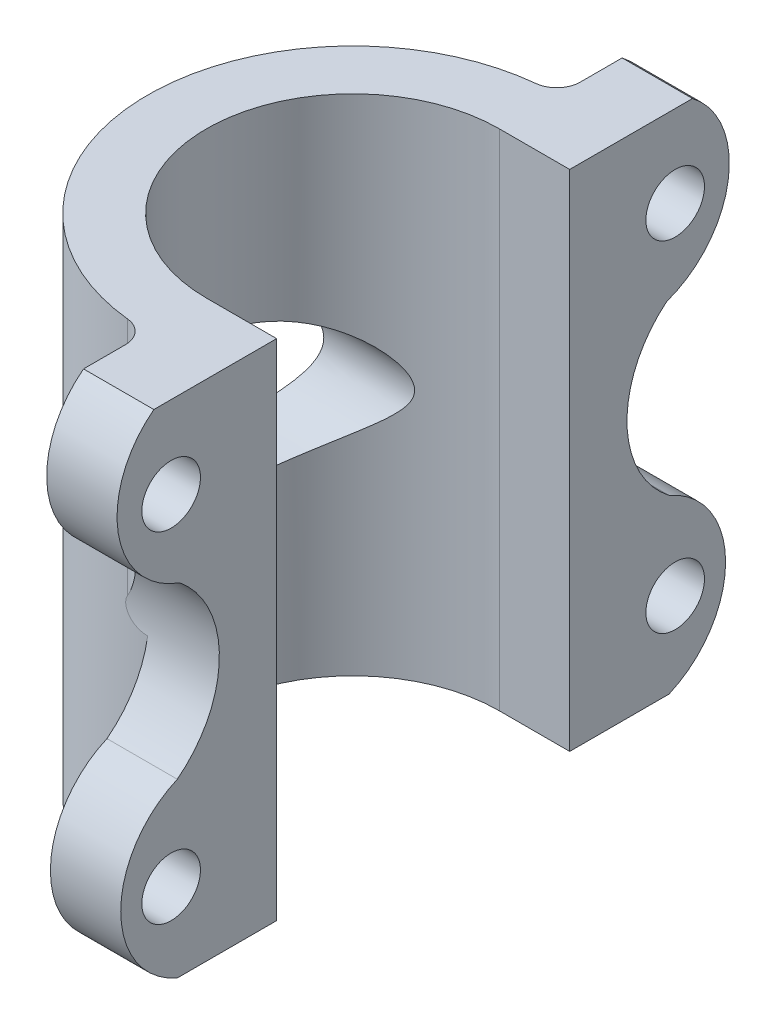
from build123d import *

# Parameters (mm, degrees)
BOSS_EXTRUDE2_DEPTH      = 21.5
CUT_EXTRUDE8_DEPTH       = 44
CUT_EXTRUDE9_DEPTH       = 24.5
SKETCH18_R               = 2.5
CUT_EXTRUDE13_DEPTH      = 18.5000001
CUT_EXTRUDE13_DEPTH_BACK = 7.0000001
SKETCH19_RX              = 11.071840333
SKETCH19_RY              = 5.954349413
CUT_EXTRUDE14_DEPTH      = 7.0000001
CUT_EXTRUDE14_DEPTH_BACK = 18.5000001
FILLET6_R                = 2
FILLET7_R                = 2


with BuildPart() as part:
    # Sketch12 → Boss-Extrude2 (new body, symmetric)
    with BuildSketch(Plane(origin=(0, 0, 0), x_dir=(1, 0, 0), z_dir=(0, 1, 0))):
        with BuildLine():
            Line((0, 35), (0, 52))
            Line((0, 52), (6, 52))
            Line((6, 52), (6, -17))
            Line((6, -17), (0, -17))
            Line((0, -17), (0, 0))
            ThreePointArc((0, 0), (-17.5, 17.5), (0, 35))
        make_face()
    extrude(amount=BOSS_EXTRUDE2_DEPTH, both=True)

    # Sketch13 → Cut-Extrude8 (cut, through all)
    with BuildSketch(Plane.XZ.offset(21.5)):
        with BuildLine():
            Line((0, -30), (6, -30))
            Line((6, -30), (6, -5))
            Line((6, -5), (0, -5))
            ThreePointArc((0, -5), (-12.5, -17.5), (0, -30))
        make_face()
    extrude(amount=-CUT_EXTRUDE8_DEPTH, mode=Mode.SUBTRACT)

    # Sketch14 → Cut-Extrude9 (cut, through all)
    with BuildSketch(Plane(origin=(6, 0, 0), x_dir=(0, 0, -1), z_dir=(1, 0, 0))):
        with BuildLine():
            Line((-3.475, -21.5), (-17, -21.5))
            Line((-17, -21.5), (-17, 21.5))
            Line((-17, 21.5), (-5.475, 21.5))
            ThreePointArc((-5.475, 21.5), (-8.517618353, 13.892451617), (-3.272109233, 7.598251675))
            ThreePointArc((-3.272109233, 7.598251675), (0.112562803, 0.342782413), (-3.475, -6.814537766))
            ThreePointArc((-3.475, -6.814537766), (-8.299421353, -14.157268883), (-3.475, -21.5))
        make_face()
    cut_extrude9 = extrude(amount=-CUT_EXTRUDE9_DEPTH, mode=Mode.SUBTRACT)

    # Mirror1: Cut-Extrude9 across plane
    add(cut_extrude9.mirror(Plane.XY.offset(-17.5)), mode=Mode.SUBTRACT)

    # Sketch18 → Cut-Extrude13 (cut, two sides)
    with BuildSketch(Plane.ZY) as cut_extrude13_sk:
        with Locations((-39, 14.5)):
            Circle(SKETCH18_R)
        with Locations((4, 14.5)):
            Circle(SKETCH18_R)
        with Locations((-39, -14.5)):
            Circle(SKETCH18_R)
        with Locations((4, -14.5)):
            Circle(SKETCH18_R)
    extrude(amount=CUT_EXTRUDE13_DEPTH, mode=Mode.SUBTRACT)
    extrude(cut_extrude13_sk.sketch, amount=-CUT_EXTRUDE13_DEPTH_BACK, mode=Mode.SUBTRACT)

    # Sketch19 → Cut-Extrude14 (cut, two sides)
    with BuildSketch(Plane(origin=(0, 0, 0), x_dir=(0, 0, -1), z_dir=(1, 0, 0))) as cut_extrude14_sk:
        with Locations(Location((17.5, 0), (0, 0, 0))):
            Ellipse(SKETCH19_RX, SKETCH19_RY)
    extrude(amount=CUT_EXTRUDE14_DEPTH, mode=Mode.SUBTRACT)
    extrude(cut_extrude14_sk.sketch, amount=-CUT_EXTRUDE14_DEPTH_BACK, mode=Mode.SUBTRACT)

    # Fillet6
    fillet6_edges = [part.edges().sort_by_distance(p)[0] for p in [
        (0, 11.706035382, 0),
    ]]
    fillet(fillet6_edges, radius=FILLET6_R)

    # Fillet7
    fillet7_edges = [part.edges().sort_by_distance(p)[0] for p in [
        (0, 11.706035382, -35),
    ]]
    fillet(fillet7_edges, radius=FILLET7_R)


solid = part.part
